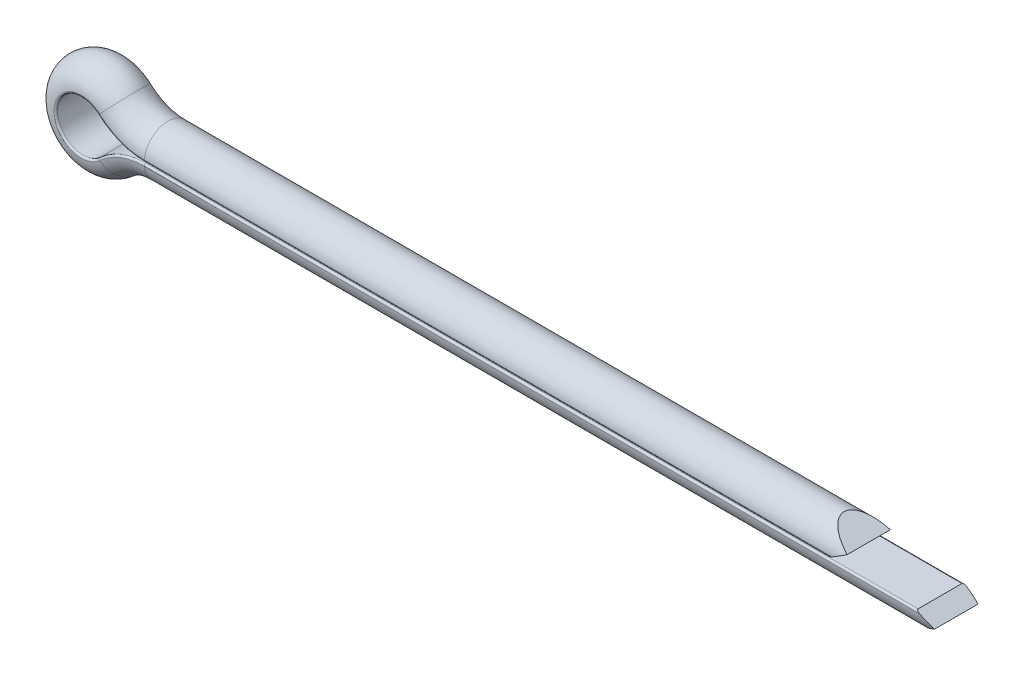
from build123d import *

# Parameters (mm, degrees)
CUT_EXTRUDE1_DEPTH      = 1.6750001
CUT_EXTRUDE1_DEPTH_BACK = 1.6750001
FILLET1_R               = 0.05


with BuildPart() as part:
    # Sweep1: sweep along a path in Sketch1
    with BuildLine(Plane.XY) as sweep1_path:
        Line((21.8, 0.7), (1.8, 0.7))
        ThreePointArc((1.8, 0.7), (1.34176437, 0.785965522), (0.945844504, 1.032171582))
        ThreePointArc((0.945844504, 1.032171582), (-1.4, 0), (0.945844504, -1.032171582))
        ThreePointArc((0.945844504, -1.032171582), (1.34176437, -0.785965522), (1.8, -0.7))
        Line((1.8, -0.7), (24.3, -0.7))
    # Sketch2 → Sweep1 (sweep)
    with BuildSketch(Plane(origin=(21.8, 0, 0), x_dir=(0, 0, -1), z_dir=(1, 0, 0))):
        with BuildLine():
            Line((0.675, 0.025), (-0.675, 0.025))
            ThreePointArc((-0.675, 0.025), (0, 0.7), (0.675, 0.025))
        make_face()
    sweep(path=sweep1_path.line)

    # Sketch3 → Cut-Extrude1 (cut, two sides)
    with BuildSketch(Plane.XY) as cut_extrude1_sk:
        Polygon((21.332346282, 0.025), (21.8, 0.295), (21.098519423, 0.7), (25.3, 0.7), (25.3, -0.7), (23.598519423, -0.7), (24.3, -0.295), (23.832346282, -0.025), (21.8, -0.025), (21.8, 0.025), align=None)
    extrude(amount=CUT_EXTRUDE1_DEPTH, mode=Mode.SUBTRACT)
    extrude(cut_extrude1_sk.sketch, amount=-CUT_EXTRUDE1_DEPTH_BACK, mode=Mode.SUBTRACT)

    # Fillet1
    fillet1_edges = [part.edges().sort_by_distance(p)[0] for p in [
        (12.816173141, -0.025, 0.675),
        (12.816173141, -0.025, -0.675),
        (1.097113144, -0.156862369, -0.675),
        (1.097113144, -0.156862369, 0.675),
        (-0.725, 0, -0.675),
        (-0.725, 0, 0.675),
        (1.097113144, 0.156862369, -0.675),
        (1.097113144, 0.156862369, 0.675),
        (11.566173141, 0.025, -0.675),
        (11.566173141, 0.025, 0.675),
    ]]
    fillet(fillet1_edges, radius=FILLET1_R)


solid = part.part
